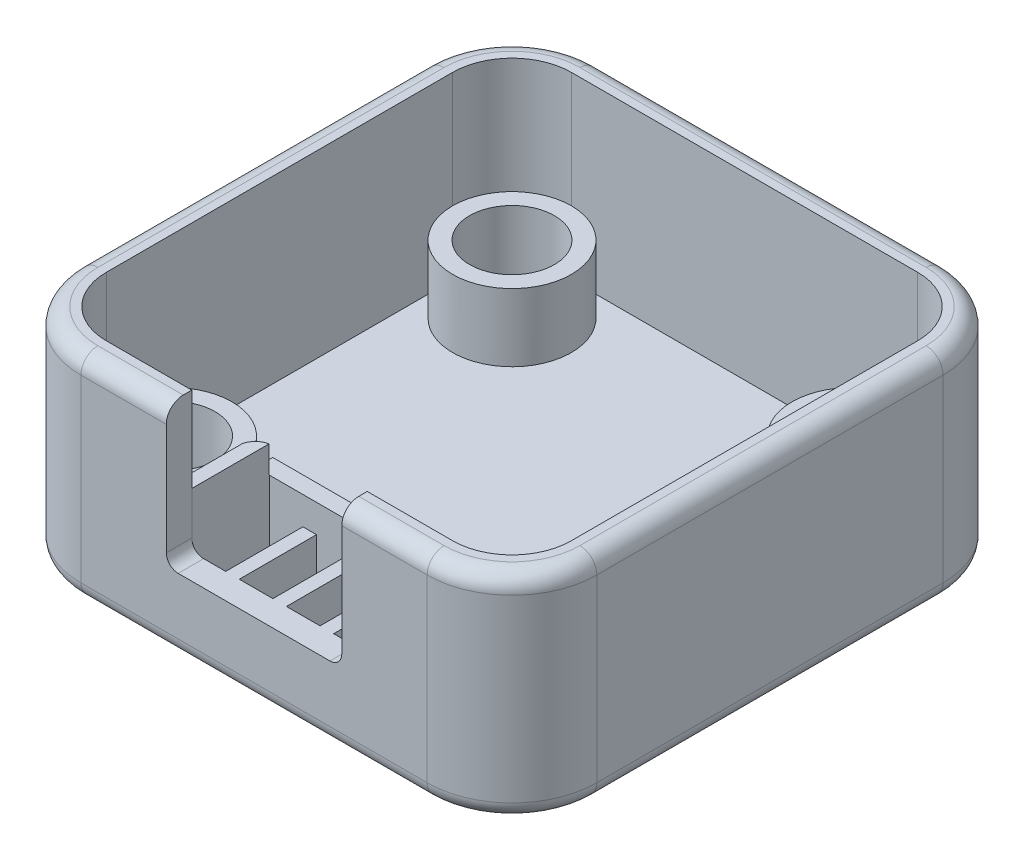
from build123d import *

# Parameters (mm, degrees)
SKETCH2_W           = 30.4
SKETCH2_H           = 30.4
BOSS_EXTRUDE1_DEPTH = 6
FILLET1_R           = 5
FILLET2_R           = 1
CUT_EXTRUDE1_DEPTH  = 0.5
BOSS_EXTRUDE2_DEPTH = 6.6
CUT_EXTRUDE2_DEPTH  = 10.6
FILLET3_R           = 1
CUT_EXTRUDE3_REACH  = 32.4
SKETCH9_W           = 0.8
SKETCH9_H           = 5.55
BOSS_EXTRUDE5_DEPTH = 2.35
LPATTERN1_COUNT     = 5
LPATTERN1_PITCH     = 2.78
SKETCH10_W          = 11.92
SKETCH10_H          = 2.35
BOSS_EXTRUDE6_DEPTH = 1
BOSS_EXTRUDE7_DEPTH = 1.65
SKETCH12_R          = 3.5
SKETCH12_R_2        = 2.5
BOSS_EXTRUDE8_DEPTH = 3.99
BOSS_EXTRUDE9_DEPTH = 1.6


with BuildPart() as part:
    # Sketch2 → Boss-Extrude1 (new body)
    with BuildSketch(Plane.XZ.offset(1.6)):
        with Locations((0, -13.5)):
            Rectangle(SKETCH2_W, SKETCH2_H)
    extrude(amount=BOSS_EXTRUDE1_DEPTH)

    # Fillet1
    fillet1_edges = [part.edges().sort_by_distance(p)[0] for p in [
        (15.2, -4.6, -28.7),
        (-15.2, -4.6, -28.7),
        (-15.2, -4.6, 1.7),
        (15.2, -4.6, 1.7),
    ]]
    fillet(fillet1_edges, radius=FILLET1_R)

    # Fillet2
    fillet2_edges = [part.edges().sort_by_distance(p)[0] for p in [
        (0, -7.6, 1.7),
        (15.2, -7.6, -13.5),
        (-15.2, -7.6, -13.5),
        (0, -7.6, -28.7),
        (-13.735533906, -7.6, -27.235533906),
        (-13.735533906, -7.6, 0.235533906),
        (13.735533906, -7.6, -27.235533906),
        (13.735533906, -7.6, 0.235533906),
    ]]
    fillet(fillet2_edges, radius=FILLET2_R)

    # Sketch3 → Cut-Extrude1 (cut)
    with BuildSketch(Plane.XZ.offset(7.6)):
        with BuildLine():
            Line((10.2, -1.8), (-10.2, -1.8))
            ThreePointArc((-10.2, -1.8), (-11.260660172, -2.239339828), (-11.7, -3.3))
            Line((-11.7, -3.3), (-11.7, -23.7))
            ThreePointArc((-11.7, -23.7), (-11.260660172, -24.760660172), (-10.2, -25.2))
            Line((-10.2, -25.2), (10.2, -25.2))
            ThreePointArc((10.2, -25.2), (11.260660172, -24.760660172), (11.7, -23.7))
            Line((11.7, -23.7), (11.7, -3.3))
            ThreePointArc((11.7, -3.3), (11.260660172, -2.239339828), (10.2, -1.8))
        make_face()
    extrude(amount=-CUT_EXTRUDE1_DEPTH, mode=Mode.SUBTRACT)

    # Sketch4 → Boss-Extrude2 (add)
    with BuildSketch(Plane(origin=(0, -1.6, 0), x_dir=(1, 0, 0), z_dir=(0, 1, 0))):
        with BuildLine():
            Line((15.2, 23.7), (15.2, 3.3))
            ThreePointArc((15.2, 3.3), (13.735533906, -0.235533906), (10.2, -1.7))
            Line((10.2, -1.7), (-10.2, -1.7))
            ThreePointArc((-10.2, -1.7), (-13.735533906, -0.235533906), (-15.2, 3.3))
            Line((-15.2, 3.3), (-15.2, 23.7))
            ThreePointArc((-15.2, 23.7), (-13.735533906, 27.235533906), (-10.2, 28.7))
            Line((-10.2, 28.7), (10.2, 28.7))
            ThreePointArc((10.2, 28.7), (13.735533906, 27.235533906), (15.2, 23.7))
        make_face()
    extrude(amount=BOSS_EXTRUDE2_DEPTH)

    # Sketch5 → Cut-Extrude2 (cut)
    with BuildSketch(Plane(origin=(0, 5, 0), x_dir=(1, 0, 0), z_dir=(0, 1, 0))):
        with BuildLine():
            Line((10.2, 27.2), (-10.2, 27.2))
            ThreePointArc((-10.2, 27.2), (-12.674873734, 26.174873734), (-13.7, 23.7))
            Line((-13.7, 23.7), (-13.7, 3.3))
            ThreePointArc((-13.7, 3.3), (-12.674873734, 0.825126266), (-10.2, -0.2))
            Line((-10.2, -0.2), (10.2, -0.2))
            ThreePointArc((10.2, -0.2), (12.674873734, 0.825126266), (13.7, 3.3))
            Line((13.7, 3.3), (13.7, 23.7))
            ThreePointArc((13.7, 23.7), (12.674873734, 26.174873734), (10.2, 27.2))
        make_face()
    extrude(amount=-CUT_EXTRUDE2_DEPTH, mode=Mode.SUBTRACT)

    # Fillet3
    fillet3_edges = [part.edges().sort_by_distance(p)[0] for p in [
        (13.735533906, 5, -27.235533906),
        (0, 5, -28.7),
        (-13.735533906, 5, -27.235533906),
        (-15.2, 5, -13.5),
        (-13.735533906, 5, 0.235533906),
        (0, 5, 1.7),
        (13.735533906, 5, 0.235533906),
        (15.2, 5, -13.5),
    ]]
    fillet(fillet3_edges, radius=FILLET3_R)

    # Sketch6 → Cut-Extrude3 (cut, up to next)
    with BuildSketch(Plane.XY.offset(1.7), mode=Mode.PRIVATE) as cut_extrude3_sk1:
        with BuildLine():
            Line((5.17, -2.55), (5.17, 5))
            Line((5.17, 5), (-5.17, 5))
            Line((-5.17, 5), (-5.17, -2.55))
            ThreePointArc((-5.17, -2.55), (-4.964974747, -3.044974747), (-4.47, -3.25))
            Line((-4.47, -3.25), (4.47, -3.25))
            ThreePointArc((4.47, -3.25), (4.964974747, -3.044974747), (5.17, -2.55))
        make_face()
    cut_extrude3_tool1 = extrude(cut_extrude3_sk1.sketch, amount=-CUT_EXTRUDE3_REACH, mode=Mode.PRIVATE) & part.part
    add(cut_extrude3_tool1.solids().sort_by_distance((0, 0.884808, 1.7))[0], mode=Mode.SUBTRACT)

    # Sketch9 → Boss-Extrude5 (add)
    with BuildSketch(Plane(origin=(0, -5.6, 0), x_dir=(1, 0, 0), z_dir=(0, 1, 0))):
        with Locations((5.57, 2.575)):
            Rectangle(SKETCH9_W, SKETCH9_H)
    boss_extrude5 = extrude(amount=BOSS_EXTRUDE5_DEPTH)

    # LPattern1: Boss-Extrude5 ×5
    with Locations(*[(-i * LPATTERN1_PITCH, 0, 0) for i in range(1, LPATTERN1_COUNT)]):
        add(boss_extrude5)

    # Sketch10 → Boss-Extrude6 (add)
    with BuildSketch(Plane(origin=(0, 0, -5.35), x_dir=(-1, 0, 0), z_dir=(0, 0, -1))):
        with Locations((-0.01, -4.425)):
            Rectangle(SKETCH10_W, SKETCH10_H)
    extrude(amount=-BOSS_EXTRUDE6_DEPTH)

    # Sketch11 → Boss-Extrude7 (add)
    with BuildSketch(Plane(origin=(0, -3.25, 0), x_dir=(1, 0, 0), z_dir=(0, 1, 0))):
        Polygon((-5.15, 4.35), (5.17, 4.35), (5.17, -0.2), (5.97, -0.2), (5.97, 5.35), (-5.95, 5.35), (-5.95, -0.2), (-5.15, -0.2), align=None)
    extrude(amount=BOSS_EXTRUDE7_DEPTH)

    # Sketch12 → Boss-Extrude8 (add)
    with BuildSketch(Plane(origin=(0, -5.6, 0), x_dir=(1, 0, 0), z_dir=(0, 1, 0))):
        with Locations((10, 3.5)):
            Circle(SKETCH12_R)
        with Locations((10, 3.5)):
            Circle(SKETCH12_R_2, mode=Mode.SUBTRACT)
        with Locations((10, 23.5)):
            Circle(SKETCH12_R)
        with Locations((10, 23.5)):
            Circle(SKETCH12_R_2, mode=Mode.SUBTRACT)
        with Locations((-10, 23.5)):
            Circle(SKETCH12_R)
        with Locations((-10, 23.5)):
            Circle(SKETCH12_R_2, mode=Mode.SUBTRACT)
        with Locations((-10, 3.5)):
            Circle(SKETCH12_R)
        with Locations((-10, 3.5)):
            Circle(SKETCH12_R_2, mode=Mode.SUBTRACT)
    extrude(amount=BOSS_EXTRUDE8_DEPTH)

    # Sketch13 → Boss-Extrude9 (add)
    with BuildSketch(Plane(origin=(0, -1.6, 0), x_dir=(1, 0, 0), z_dir=(0, 1, 0))):
        with BuildLine():
            Line((-5.95, -0.2), (-5.15, -0.2))
            Line((-5.15, -0.2), (-5.15, 4.33366661))
            ThreePointArc((-5.15, 4.33366661), (-5.67023311, 4.063914275), (-5.95, 3.548997487))
            Line((-5.95, 3.548997487), (-5.95, -0.2))
        make_face()
        with BuildLine():
            Line((5.17, -0.2), (5.97, -0.2))
            Line((5.97, -0.2), (5.97, 3.35))
            ThreePointArc((5.97, 3.35), (5.744596669, 3.982455532), (5.17, 4.329795897))
            Line((5.17, 4.329795897), (5.17, -0.2))
        make_face()
    extrude(amount=BOSS_EXTRUDE9_DEPTH)


solid = part.part
